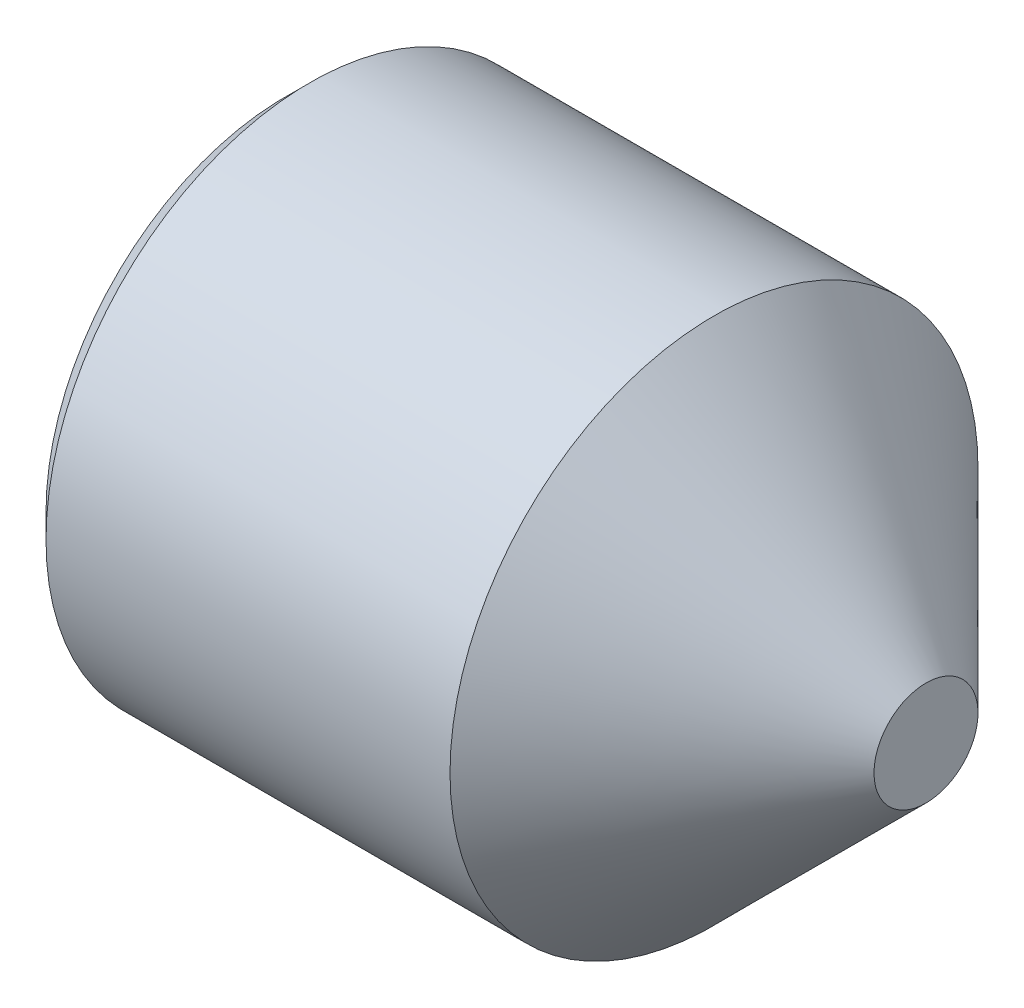
from build123d import *

# Parameters (mm, degrees)
HEXAGONSOCKET_DEPTH = 1.2


with BuildPart() as part:
    # Sketch1 → Base (revolve)
    with BuildSketch(Plane.XY):
        Polygon((0, 0), (4, 0), (4, 0.325), (2.675, 1.65), (0.15, 1.65), (0, 1.5), align=None)
    revolve(axis=Axis((-14.774129749, 0, 0), (1, 0, 0)))

    # Sketch2 → HexagonSocket (cut)
    with BuildSketch(Plane(origin=(0, 0.220293087, -0.139195271), x_dir=(0, 0, 1), z_dir=(-1, 0, 0))):
        Polygon((0.889750621, -0.220293087), (0.514472946, 0.429706913), (-0.236082404, 0.429706913), (-0.611360079, -0.220293087), (-0.236082404, -0.870293087), (0.514472946, -0.870293087), align=None)
    extrude(amount=-HEXAGONSOCKET_DEPTH, mode=Mode.SUBTRACT)

    # Sketch3 → Cut-Revolve (revolve, cut)
    with BuildSketch(Plane.XY):
        Polygon((1.2, 0.65), (1.575277675, 0), (1.2, 0), align=None)
    revolve(axis=Axis((1.2, 0, 0), (-1, 0, 0)), mode=Mode.SUBTRACT)


solid = part.part
